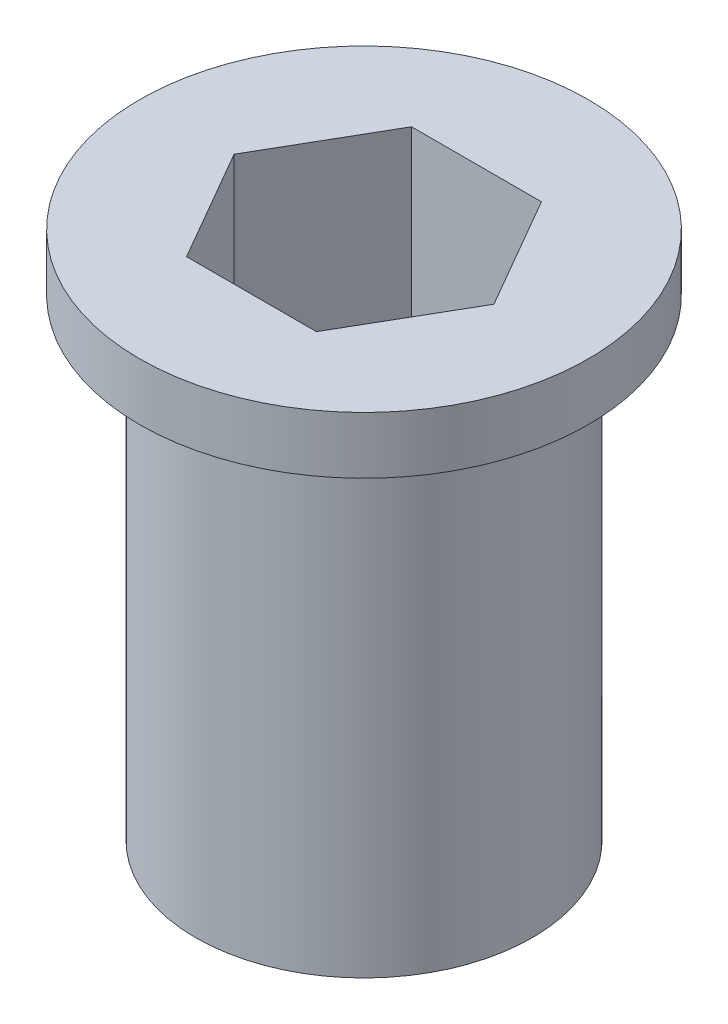
from build123d import *

# Parameters (mm, degrees)
SKETCH1_R           = 7.5
BOSS_EXTRUDE1_DEPTH = 21.05
SKETCH1_3_R         = 10
BOSS_EXTRUDE2_DEPTH = 2.54


with BuildPart() as part:
    # Sketch1 → Boss-Extrude1 (new body)
    with BuildSketch(Plane(origin=(0, 0, 0), x_dir=(1, 0, 0), z_dir=(0, 1, 0))):
        Circle(SKETCH1_R)
        Polygon((2.893968224, -5.0125), (-2.893968224, -5.0125), (-5.787936449, 0), (-2.893968224, 5.0125), (2.893968224, 5.0125), (5.787936449, 0), align=None, mode=Mode.SUBTRACT)
    extrude(amount=-BOSS_EXTRUDE1_DEPTH)

    # Sketch1_3 → Boss-Extrude2 (add)
    with BuildSketch(Plane(origin=(0, 0, 0), x_dir=(1, 0, 0), z_dir=(0, 1, 0))):
        Circle(SKETCH1_3_R)
        Polygon((2.893968224, -5.0125), (-2.893968224, -5.0125), (-5.787936449, 0), (-2.893968224, 5.0125), (2.893968224, 5.0125), (5.787936449, 0), align=None, mode=Mode.SUBTRACT)
    extrude(amount=BOSS_EXTRUDE2_DEPTH)


solid = part.part
